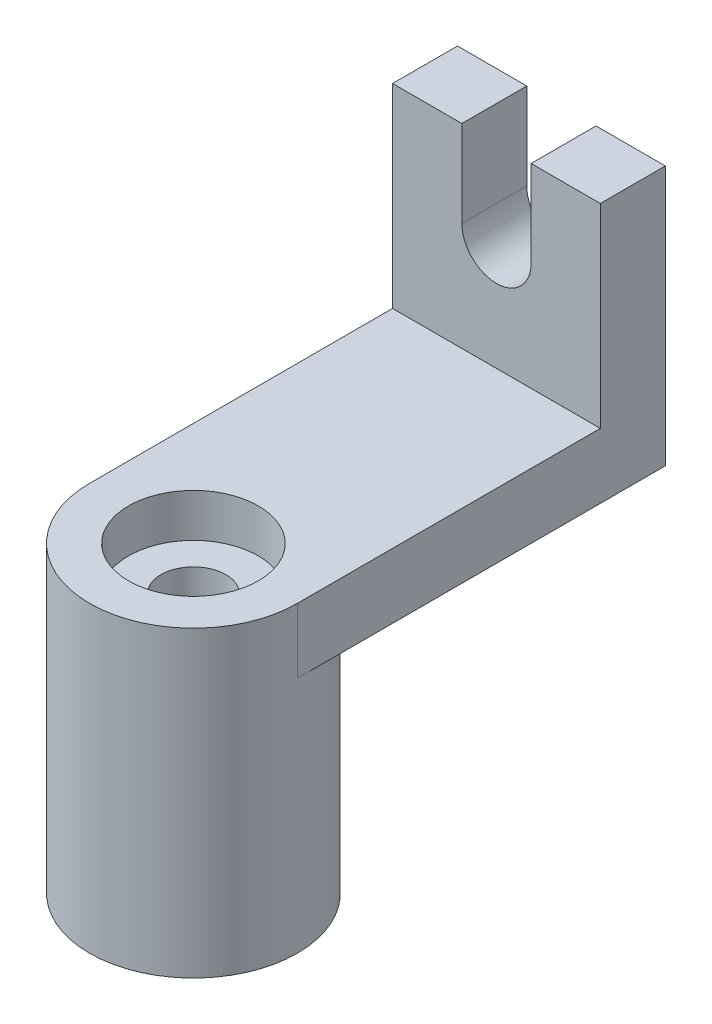
from build123d import *

# Parameters (mm, degrees)
SKETCH1_R           = 24
SKETCH1_R_2         = 7.5
BOSS_EXTRUDE1_DEPTH = 70
BOSS_EXTRUDE3_DEPTH = 24
SKETCH3_R           = 7.5
CUT_EXTRUDE1_DEPTH  = 48
SKETCH4_R           = 15
CUT_EXTRUDE2_DEPTH  = 10
SKETCH5_R           = 15
CUT_EXTRUDE3_DEPTH  = 10
CUT_EXTRUDE4_DEPTH  = 20


with BuildPart() as part:
    # Sketch1 → Boss-Extrude1 (new body)
    with BuildSketch(Plane(origin=(0, 0, 0), x_dir=(1, 0, 0), z_dir=(0, 1, 0))):
        with Locations(Location((0, 0, 0), (0, 0, 270))):
            Circle(SKETCH1_R)
        with Locations(Location((0, 0, 0), (0, 0, 270))):
            Circle(SKETCH1_R_2, mode=Mode.SUBTRACT)
    extrude(amount=BOSS_EXTRUDE1_DEPTH)

    # Sketch2 → Boss-Extrude3 (add, symmetric)
    with BuildSketch(Plane(origin=(0, 0, 0), x_dir=(0, 0, -1), z_dir=(1, 0, 0))):
        Polygon((0, 55), (85, 55), (85, 115), (70, 115), (70, 70), (0, 70), align=None)
    extrude(amount=BOSS_EXTRUDE3_DEPTH, both=True)

    # Sketch3 → Cut-Extrude1 (cut)
    with BuildSketch(Plane(origin=(0, 55, 0), x_dir=(-1, 0, 0), z_dir=(0, -1, 0))):
        with Locations(Location((0, 0, 0), (0, 0, 270))):
            Circle(SKETCH3_R)
    extrude(amount=-CUT_EXTRUDE1_DEPTH, mode=Mode.SUBTRACT)

    # Sketch4 → Cut-Extrude2 (cut)
    with BuildSketch(Plane(origin=(0, 70, 0), x_dir=(1, 0, 0), z_dir=(0, 1, 0))):
        with Locations(Location((0, 0, 0), (0, 0, 270))):
            Circle(SKETCH4_R)
    extrude(amount=-CUT_EXTRUDE2_DEPTH, mode=Mode.SUBTRACT)

    # Sketch5 → Cut-Extrude3 (cut)
    with BuildSketch(Plane.XZ):
        with Locations(Location((0, 0, 0), (0, 0, 90))):
            Circle(SKETCH5_R)
    extrude(amount=-CUT_EXTRUDE3_DEPTH, mode=Mode.SUBTRACT)

    # Sketch6 → Cut-Extrude4 (cut)
    with BuildSketch(Plane(origin=(0, 0, -85), x_dir=(-1, 0, 0), z_dir=(0, 0, -1))):
        with BuildLine():
            Line((-8, 95), (-8, 115))
            Line((-8, 115), (8, 115))
            Line((8, 115), (8, 95))
            ThreePointArc((8, 95), (0, 87), (-8, 95))
        make_face()
    extrude(amount=-CUT_EXTRUDE4_DEPTH, mode=Mode.SUBTRACT)


solid = part.part
